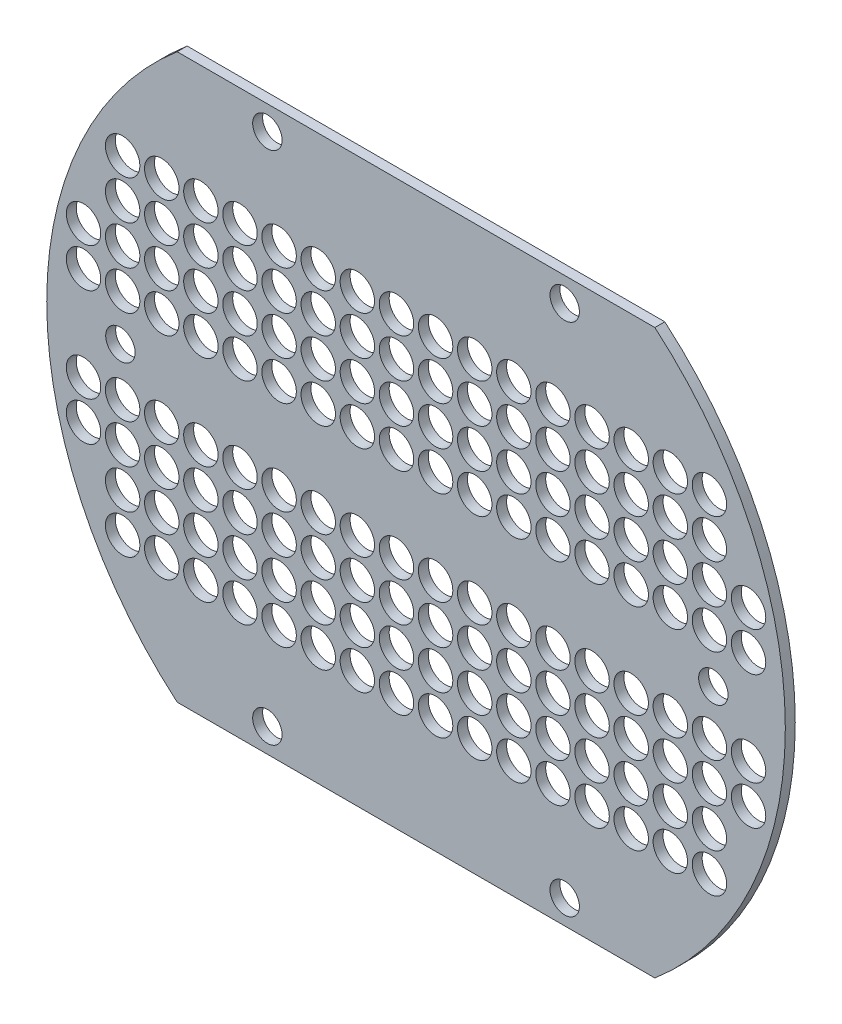
from build123d import *

# Parameters (mm, degrees)
SKETCH1_R           = 11
SKETCH1_R_2         = 9.398
BOSS_EXTRUDE1_DEPTH = 3.175


with BuildPart() as part:
    # Sketch1 → Boss-Extrude1 (new body, symmetric)
    with BuildSketch(Plane.XY):
        with BuildLine():
            Line((-150.612138354, 155.917155483), (154.648406099, 155.917155483))
            ThreePointArc((154.648406099, 155.917155483), (228.618803712, 41.857556062), (227.397894844, -94.082582693))
            ThreePointArc((227.397894844, -94.082582693), (233.57515605, -69.660750134), (237.114122078, -44.719615817))
            ThreePointArc((237.114122078, -44.719615817), (211.61792615, -132.544483254), (154.648406099, -204.082844517))
            Line((154.648406099, -204.082844517), (-150.612138354, -204.082844517))
            ThreePointArc((-150.612138354, -204.082844517), (-207.581658404, -132.544483254), (-233.077854333, -44.719615817))
            ThreePointArc((-233.077854333, -44.719615817), (-229.538888305, -69.660750134), (-223.361627098, -94.082582693))
            ThreePointArc((-223.361627098, -94.082582693), (-224.582535966, 41.857556062), (-150.612138354, 155.917155483))
        make_face()
        with Locations((-210.481866127, -79.082844517)):
            Circle(SKETCH1_R, mode=Mode.SUBTRACT)
        with Locations((-185.481866127, -79.082844517)):
            Circle(SKETCH1_R, mode=Mode.SUBTRACT)
        with Locations((-135.481866127, -79.082844517)):
            Circle(SKETCH1_R, mode=Mode.SUBTRACT)
        with Locations((-110.481866127, -79.082844517)):
            Circle(SKETCH1_R, mode=Mode.SUBTRACT)
        with Locations((-85.481866127, -79.082844517)):
            Circle(SKETCH1_R, mode=Mode.SUBTRACT)
        with Locations((-60.481866127, -79.082844517)):
            Circle(SKETCH1_R, mode=Mode.SUBTRACT)
        with Locations((-35.481866127, -79.082844517)):
            Circle(SKETCH1_R, mode=Mode.SUBTRACT)
        with Locations((-10.481866127, -79.082844517)):
            Circle(SKETCH1_R, mode=Mode.SUBTRACT)
        with Locations((214.518133873, -79.082844517)):
            Circle(SKETCH1_R, mode=Mode.SUBTRACT)
        with Locations((214.518133873, -54.082844517)):
            Circle(SKETCH1_R, mode=Mode.SUBTRACT)
        with Locations((189.518133873, -79.082844517)):
            Circle(SKETCH1_R, mode=Mode.SUBTRACT)
        with Locations((189.518133873, -54.082844517)):
            Circle(SKETCH1_R, mode=Mode.SUBTRACT)
        with Locations((164.518133873, -54.082844517)):
            Circle(SKETCH1_R, mode=Mode.SUBTRACT)
        with Locations((164.518133873, -79.082844517)):
            Circle(SKETCH1_R, mode=Mode.SUBTRACT)
        with Locations((139.518133873, -79.082844517)):
            Circle(SKETCH1_R, mode=Mode.SUBTRACT)
        with Locations((139.518133873, -54.082844517)):
            Circle(SKETCH1_R, mode=Mode.SUBTRACT)
        with Locations((114.518133873, -54.082844517)):
            Circle(SKETCH1_R, mode=Mode.SUBTRACT)
        with Locations((114.518133873, -79.082844517)):
            Circle(SKETCH1_R, mode=Mode.SUBTRACT)
        with Locations((89.518133873, -79.082844517)):
            Circle(SKETCH1_R, mode=Mode.SUBTRACT)
        with Locations((89.518133873, -54.082844517)):
            Circle(SKETCH1_R, mode=Mode.SUBTRACT)
        with Locations((64.518133873, -79.082844517)):
            Circle(SKETCH1_R, mode=Mode.SUBTRACT)
        with Locations((64.518133873, -54.082844517)):
            Circle(SKETCH1_R, mode=Mode.SUBTRACT)
        with Locations((39.518133873, -79.082844517)):
            Circle(SKETCH1_R, mode=Mode.SUBTRACT)
        with Locations((39.518133873, -54.082844517)):
            Circle(SKETCH1_R, mode=Mode.SUBTRACT)
        with Locations((14.518133873, -54.082844517)):
            Circle(SKETCH1_R, mode=Mode.SUBTRACT)
        with Locations((-10.481866127, -54.082844517)):
            Circle(SKETCH1_R, mode=Mode.SUBTRACT)
        with Locations((-35.481866127, -54.082844517)):
            Circle(SKETCH1_R, mode=Mode.SUBTRACT)
        with Locations((-60.481866127, -54.082844517)):
            Circle(SKETCH1_R, mode=Mode.SUBTRACT)
        with Locations((-85.481866127, -54.082844517)):
            Circle(SKETCH1_R, mode=Mode.SUBTRACT)
        with Locations((-110.481866127, -54.082844517)):
            Circle(SKETCH1_R, mode=Mode.SUBTRACT)
        with Locations((-135.481866127, -54.082844517)):
            Circle(SKETCH1_R, mode=Mode.SUBTRACT)
        with Locations((-160.481866127, -54.082844517)):
            Circle(SKETCH1_R, mode=Mode.SUBTRACT)
        with Locations((-185.481866127, -54.082844517)):
            Circle(SKETCH1_R, mode=Mode.SUBTRACT)
        with Locations((-210.481866127, -54.082844517)):
            Circle(SKETCH1_R, mode=Mode.SUBTRACT)
        with Locations((97.018133873, 140.461982202)):
            Circle(SKETCH1_R_2, mode=Mode.SUBTRACT)
        with Locations((-92.981866127, 140.461982202)):
            Circle(SKETCH1_R_2, mode=Mode.SUBTRACT)
        with Locations((-60.481866127, 5.917155483)):
            Circle(SKETCH1_R, mode=Mode.SUBTRACT)
        with Locations((-35.481866127, 5.917155483)):
            Circle(SKETCH1_R, mode=Mode.SUBTRACT)
        with Locations((-35.481866127, 30.917155483)):
            Circle(SKETCH1_R, mode=Mode.SUBTRACT)
        with Locations((-60.481866127, 30.917155483)):
            Circle(SKETCH1_R, mode=Mode.SUBTRACT)
        with Locations((-60.481866127, 55.917155483)):
            Circle(SKETCH1_R, mode=Mode.SUBTRACT)
        with Locations((-35.481866127, 55.917155483)):
            Circle(SKETCH1_R, mode=Mode.SUBTRACT)
        with Locations((-10.481866127, 55.917155483)):
            Circle(SKETCH1_R, mode=Mode.SUBTRACT)
        with Locations((-10.481866127, 30.917155483)):
            Circle(SKETCH1_R, mode=Mode.SUBTRACT)
        with Locations((-10.481866127, 5.917155483)):
            Circle(SKETCH1_R, mode=Mode.SUBTRACT)
        with Locations((14.518133873, 5.917155483)):
            Circle(SKETCH1_R, mode=Mode.SUBTRACT)
        with Locations((14.518133873, 30.917155483)):
            Circle(SKETCH1_R, mode=Mode.SUBTRACT)
        with Locations((14.518133873, 55.917155483)):
            Circle(SKETCH1_R, mode=Mode.SUBTRACT)
        with Locations((39.518133873, 55.917155483)):
            Circle(SKETCH1_R, mode=Mode.SUBTRACT)
        with Locations((39.518133873, 30.917155483)):
            Circle(SKETCH1_R, mode=Mode.SUBTRACT)
        with Locations((39.518133873, 5.917155483)):
            Circle(SKETCH1_R, mode=Mode.SUBTRACT)
        with Locations((64.518133873, 5.917155483)):
            Circle(SKETCH1_R, mode=Mode.SUBTRACT)
        with Locations((64.518133873, 55.917155483)):
            Circle(SKETCH1_R, mode=Mode.SUBTRACT)
        with Locations((64.518133873, 30.917155483)):
            Circle(SKETCH1_R, mode=Mode.SUBTRACT)
        with Locations((89.518133873, 30.917155483)):
            Circle(SKETCH1_R, mode=Mode.SUBTRACT)
        with Locations((89.518133873, 5.917155483)):
            Circle(SKETCH1_R, mode=Mode.SUBTRACT)
        with Locations((89.518133873, 55.917155483)):
            Circle(SKETCH1_R, mode=Mode.SUBTRACT)
        with Locations((114.518133873, 55.917155483)):
            Circle(SKETCH1_R, mode=Mode.SUBTRACT)
        with Locations((114.518133873, 30.917155483)):
            Circle(SKETCH1_R, mode=Mode.SUBTRACT)
        with Locations((114.518133873, 5.917155483)):
            Circle(SKETCH1_R, mode=Mode.SUBTRACT)
        with Locations((139.518133873, 5.917155483)):
            Circle(SKETCH1_R, mode=Mode.SUBTRACT)
        with Locations((139.518133873, 30.917155483)):
            Circle(SKETCH1_R, mode=Mode.SUBTRACT)
        with Locations((139.518133873, 55.917155483)):
            Circle(SKETCH1_R, mode=Mode.SUBTRACT)
        with Locations((164.518133873, 55.917155483)):
            Circle(SKETCH1_R, mode=Mode.SUBTRACT)
        with Locations((164.518133873, 30.917155483)):
            Circle(SKETCH1_R, mode=Mode.SUBTRACT)
        with Locations((164.518133873, 5.917155483)):
            Circle(SKETCH1_R, mode=Mode.SUBTRACT)
        with Locations((189.518133873, 5.917155483)):
            Circle(SKETCH1_R, mode=Mode.SUBTRACT)
        with Locations((214.518133873, 5.917155483)):
            Circle(SKETCH1_R, mode=Mode.SUBTRACT)
        with Locations((214.518133873, 30.917155483)):
            Circle(SKETCH1_R, mode=Mode.SUBTRACT)
        with Locations((189.518133873, 30.917155483)):
            Circle(SKETCH1_R, mode=Mode.SUBTRACT)
        with Locations((189.518133873, 55.917155483)):
            Circle(SKETCH1_R, mode=Mode.SUBTRACT)
        with Locations((189.518133873, 80.917155483)):
            Circle(SKETCH1_R, mode=Mode.SUBTRACT)
        with Locations((164.518133873, 80.917155483)):
            Circle(SKETCH1_R, mode=Mode.SUBTRACT)
        with Locations((139.518133873, 80.917155483)):
            Circle(SKETCH1_R, mode=Mode.SUBTRACT)
        with Locations((114.518133873, 80.917155483)):
            Circle(SKETCH1_R, mode=Mode.SUBTRACT)
        with Locations((89.518133873, 80.917155483)):
            Circle(SKETCH1_R, mode=Mode.SUBTRACT)
        with Locations((64.518133873, 80.917155483)):
            Circle(SKETCH1_R, mode=Mode.SUBTRACT)
        with Locations((39.518133873, 80.917155483)):
            Circle(SKETCH1_R, mode=Mode.SUBTRACT)
        with Locations((14.518133873, 80.917155483)):
            Circle(SKETCH1_R, mode=Mode.SUBTRACT)
        with Locations((-10.481866127, 80.917155483)):
            Circle(SKETCH1_R, mode=Mode.SUBTRACT)
        with Locations((-35.481866127, 80.917155483)):
            Circle(SKETCH1_R, mode=Mode.SUBTRACT)
        with Locations((-60.481866127, 80.917155483)):
            Circle(SKETCH1_R, mode=Mode.SUBTRACT)
        with Locations((-85.481866127, 80.917155483)):
            Circle(SKETCH1_R, mode=Mode.SUBTRACT)
        with Locations((-85.481866127, 55.917155483)):
            Circle(SKETCH1_R, mode=Mode.SUBTRACT)
        with Locations((-85.481866127, 30.917155483)):
            Circle(SKETCH1_R, mode=Mode.SUBTRACT)
        with Locations((-85.481866127, 5.917155483)):
            Circle(SKETCH1_R, mode=Mode.SUBTRACT)
        with Locations((-110.481866127, 5.917155483)):
            Circle(SKETCH1_R, mode=Mode.SUBTRACT)
        with Locations((-110.481866127, 30.917155483)):
            Circle(SKETCH1_R, mode=Mode.SUBTRACT)
        with Locations((-110.481866127, 55.917155483)):
            Circle(SKETCH1_R, mode=Mode.SUBTRACT)
        with Locations((-110.481866127, 80.917155483)):
            Circle(SKETCH1_R, mode=Mode.SUBTRACT)
        with Locations((-135.481866127, 80.917155483)):
            Circle(SKETCH1_R, mode=Mode.SUBTRACT)
        with Locations((-135.481866127, 55.917155483)):
            Circle(SKETCH1_R, mode=Mode.SUBTRACT)
        with Locations((-135.481866127, 30.917155483)):
            Circle(SKETCH1_R, mode=Mode.SUBTRACT)
        with Locations((-135.481866127, 5.917155483)):
            Circle(SKETCH1_R, mode=Mode.SUBTRACT)
        with Locations((-160.481866127, 5.917155483)):
            Circle(SKETCH1_R, mode=Mode.SUBTRACT)
        with Locations((-160.481866127, 30.917155483)):
            Circle(SKETCH1_R, mode=Mode.SUBTRACT)
        with Locations((-160.481866127, 80.917155483)):
            Circle(SKETCH1_R, mode=Mode.SUBTRACT)
        with Locations((-185.481866127, 55.917155483)):
            Circle(SKETCH1_R, mode=Mode.SUBTRACT)
        with Locations((-160.481866127, 55.917155483)):
            Circle(SKETCH1_R, mode=Mode.SUBTRACT)
        with Locations((-185.481866127, 80.917155483)):
            Circle(SKETCH1_R, mode=Mode.SUBTRACT)
        with Locations((-185.481866127, 30.917155483)):
            Circle(SKETCH1_R, mode=Mode.SUBTRACT)
        with Locations((-185.481866127, 5.917155483)):
            Circle(SKETCH1_R, mode=Mode.SUBTRACT)
        with Locations((-210.481866127, 5.917155483)):
            Circle(SKETCH1_R, mode=Mode.SUBTRACT)
        with Locations((-210.481866127, 30.917155483)):
            Circle(SKETCH1_R, mode=Mode.SUBTRACT)
        with Locations((-160.481866127, -79.082844517)):
            Circle(SKETCH1_R, mode=Mode.SUBTRACT)
        with Locations((14.518133873, -79.082844517)):
            Circle(SKETCH1_R, mode=Mode.SUBTRACT)
        with Locations((-186.89204682, -24.082844517)):
            Circle(SKETCH1_R_2, mode=Mode.SUBTRACT)
        with Locations((192.009704886, -24.082844517)):
            Circle(SKETCH1_R_2, mode=Mode.SUBTRACT)
        with Locations((-185.481866127, -129.082844517)):
            Circle(SKETCH1_R, mode=Mode.SUBTRACT)
        with Locations((-160.481866127, -104.082844517)):
            Circle(SKETCH1_R, mode=Mode.SUBTRACT)
        with Locations((-185.481866127, -104.082844517)):
            Circle(SKETCH1_R, mode=Mode.SUBTRACT)
        with Locations((-160.481866127, -129.082844517)):
            Circle(SKETCH1_R, mode=Mode.SUBTRACT)
        with Locations((-135.481866127, -104.082844517)):
            Circle(SKETCH1_R, mode=Mode.SUBTRACT)
        with Locations((-135.481866127, -129.082844517)):
            Circle(SKETCH1_R, mode=Mode.SUBTRACT)
        with Locations((-110.481866127, -129.082844517)):
            Circle(SKETCH1_R, mode=Mode.SUBTRACT)
        with Locations((-110.481866127, -104.082844517)):
            Circle(SKETCH1_R, mode=Mode.SUBTRACT)
        with Locations((-85.481866127, -104.082844517)):
            Circle(SKETCH1_R, mode=Mode.SUBTRACT)
        with Locations((-85.481866127, -129.082844517)):
            Circle(SKETCH1_R, mode=Mode.SUBTRACT)
        with Locations((-60.481866127, -129.082844517)):
            Circle(SKETCH1_R, mode=Mode.SUBTRACT)
        with Locations((-35.481866127, -129.082844517)):
            Circle(SKETCH1_R, mode=Mode.SUBTRACT)
        with Locations((-10.481866127, -129.082844517)):
            Circle(SKETCH1_R, mode=Mode.SUBTRACT)
        with Locations((14.518133873, -129.082844517)):
            Circle(SKETCH1_R, mode=Mode.SUBTRACT)
        with Locations((39.518133873, -129.082844517)):
            Circle(SKETCH1_R, mode=Mode.SUBTRACT)
        with Locations((64.518133873, -129.082844517)):
            Circle(SKETCH1_R, mode=Mode.SUBTRACT)
        with Locations((89.518133873, -129.082844517)):
            Circle(SKETCH1_R, mode=Mode.SUBTRACT)
        with Locations((114.518133873, -129.082844517)):
            Circle(SKETCH1_R, mode=Mode.SUBTRACT)
        with Locations((139.518133873, -129.082844517)):
            Circle(SKETCH1_R, mode=Mode.SUBTRACT)
        with Locations((164.518133873, -129.082844517)):
            Circle(SKETCH1_R, mode=Mode.SUBTRACT)
        with Locations((189.518133873, -129.082844517)):
            Circle(SKETCH1_R, mode=Mode.SUBTRACT)
        with Locations((189.518133873, -104.082844517)):
            Circle(SKETCH1_R, mode=Mode.SUBTRACT)
        with Locations((164.518133873, -104.082844517)):
            Circle(SKETCH1_R, mode=Mode.SUBTRACT)
        with Locations((139.518133873, -104.082844517)):
            Circle(SKETCH1_R, mode=Mode.SUBTRACT)
        with Locations((114.518133873, -104.082844517)):
            Circle(SKETCH1_R, mode=Mode.SUBTRACT)
        with Locations((89.518133873, -104.082844517)):
            Circle(SKETCH1_R, mode=Mode.SUBTRACT)
        with Locations((64.518133873, -104.082844517)):
            Circle(SKETCH1_R, mode=Mode.SUBTRACT)
        with Locations((39.518133873, -104.082844517)):
            Circle(SKETCH1_R, mode=Mode.SUBTRACT)
        with Locations((14.518133873, -104.082844517)):
            Circle(SKETCH1_R, mode=Mode.SUBTRACT)
        with Locations((-10.481866127, -104.082844517)):
            Circle(SKETCH1_R, mode=Mode.SUBTRACT)
        with Locations((-35.481866127, -104.082844517)):
            Circle(SKETCH1_R, mode=Mode.SUBTRACT)
        with Locations((-60.481866127, -104.082844517)):
            Circle(SKETCH1_R, mode=Mode.SUBTRACT)
        with Locations((-92.981866127, -188.627671236)):
            Circle(SKETCH1_R_2, mode=Mode.SUBTRACT)
        with Locations((97.018133873, -188.627671236)):
            Circle(SKETCH1_R_2, mode=Mode.SUBTRACT)
    extrude(amount=BOSS_EXTRUDE1_DEPTH, both=True)


solid = part.part
